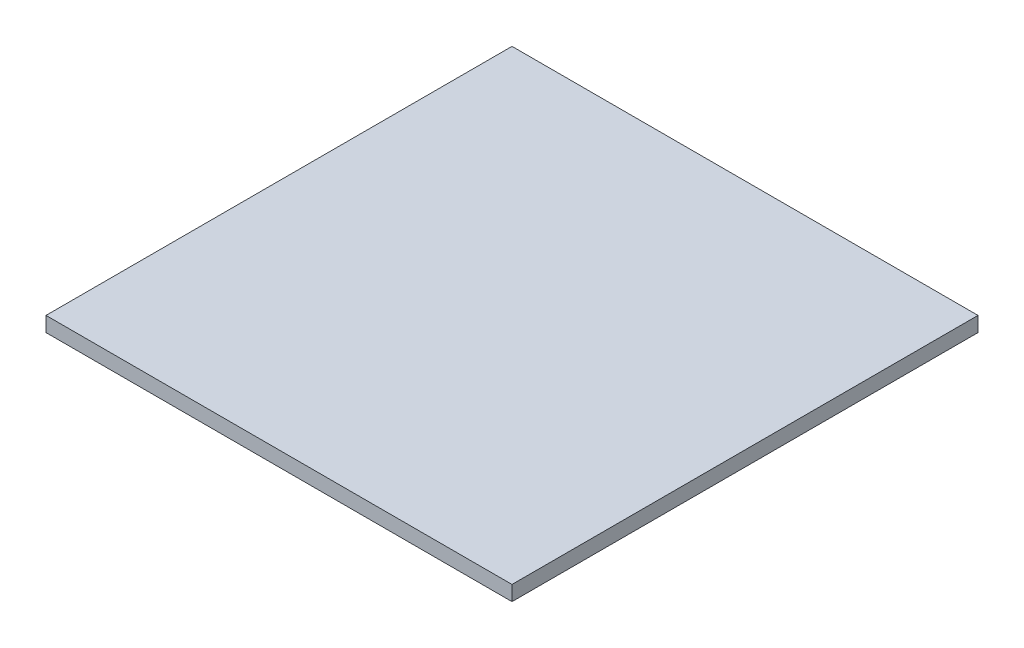
from build123d import *

# Parameters (mm, degrees)
SKETCH1_W           = 50
SKETCH1_H           = 50
BOSS_EXTRUDE1_DEPTH = 1.6


with BuildPart() as part:
    # Sketch1 → Boss-Extrude1 (new body)
    with BuildSketch(Plane(origin=(0, 0, 0), x_dir=(1, 0, 0), z_dir=(0, 1, 0))):
        Rectangle(SKETCH1_W, SKETCH1_H)
    extrude(amount=BOSS_EXTRUDE1_DEPTH)


solid = part.part
